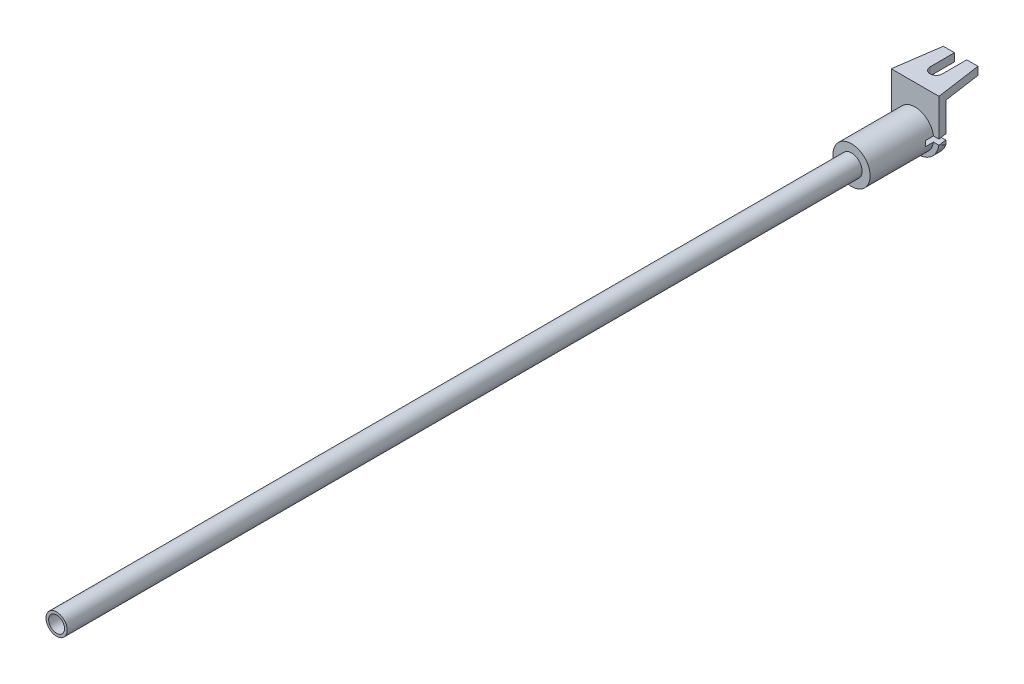
from build123d import *

# Parameters (mm, degrees)
ESQUISSE1_R             = 3.5
ESQUISSE1_R_2           = 1
BASE_EXTRUSION_DEPTH    = 12
ESQUISSE2_R             = 2
ESQUISSE2_R_2           = 1.5
BOSS_EXTRU_1_DEPTH      = 150
BOSS_EXTRU_2_DEPTH      = 4.5
CONG_1_R                = 4
ESQUISSE4_W             = 7
ESQUISSE4_H             = 1
ENL_V_MAT_EXTRU_1_DEPTH = 3
ENL_V_MAT_EXTRU_2_DEPTH = 12.5


with BuildPart() as part:
    # Esquisse1 → Base-Extrusion (new body)
    with BuildSketch(Plane.XY):
        Circle(ESQUISSE1_R)
        Circle(ESQUISSE1_R_2, mode=Mode.SUBTRACT)
    extrude(amount=BASE_EXTRUSION_DEPTH)

    # Esquisse2 → Boss.-Extru.1 (add)
    with BuildSketch(Plane.XY.offset(12)):
        Circle(ESQUISSE2_R)
        Circle(ESQUISSE2_R_2, mode=Mode.SUBTRACT)
    extrude(amount=BOSS_EXTRU_1_DEPTH)

    # Esquisse3 → Boss.-Extru.2 (add, symmetric)
    with BuildSketch(Plane(origin=(0, 0, 0), x_dir=(0, 0, -1), z_dir=(1, 0, 0))):
        Polygon((0, 0), (0, 7.5), (11.5, 7.5), (11.5, 6), (1.5, 6), (1.5, -4), (0, -4), align=None)
    extrude(amount=BOSS_EXTRU_2_DEPTH, both=True)

    # Congé1
    cong_1_edges = [part.edges().sort_by_distance(p)[0] for p in [
        (4.5, -4, -0.75),
        (-4.5, -4, -0.75),
    ]]
    fillet(cong_1_edges, radius=CONG_1_R)

    # Esquisse4 → Enlèv. mat.-Extru.1 (cut)
    with BuildSketch(Plane(origin=(0, 0, -1.5), x_dir=(-1, 0, 0), z_dir=(0, 0, -1))):
        with Locations((-3.5, 0)):
            Rectangle(ESQUISSE4_W, ESQUISSE4_H)
    extrude(amount=-ENL_V_MAT_EXTRU_1_DEPTH, mode=Mode.SUBTRACT)

    # Esquisse5 → Enlèv. mat.-Extru.2 (cut, through all)
    with BuildSketch(Plane(origin=(0, 7.5, 0), x_dir=(-1, 0, 0), z_dir=(0, 1, 0))):
        with BuildLine():
            Line((1.155842945, -8.594721571), (1.155842945, -3.98824613))
            ThreePointArc((1.155842945, -3.98824613), (0, -2.832403184), (-1.155842945, -3.98824613))
            Line((-1.155842945, -3.98824613), (-1.155842945, -8.594721571))
            Line((-1.155842945, -8.594721571), (-3.272534799, -8.594721571))
            Line((-3.272534799, -8.594721571), (-4.5, 0))
            Line((-4.5, 0), (-6, 0))
            Line((-6, 0), (-6, -13))
            Line((-6, -13), (6, -13))
            Line((6, -13), (6, 0))
            Line((6, 0), (4.5, 0))
            Line((4.5, 0), (3.272534799, -8.594721571))
            Line((3.272534799, -8.594721571), (1.155842945, -8.594721571))
        make_face()
    extrude(amount=-ENL_V_MAT_EXTRU_2_DEPTH, mode=Mode.SUBTRACT)


solid = part.part
